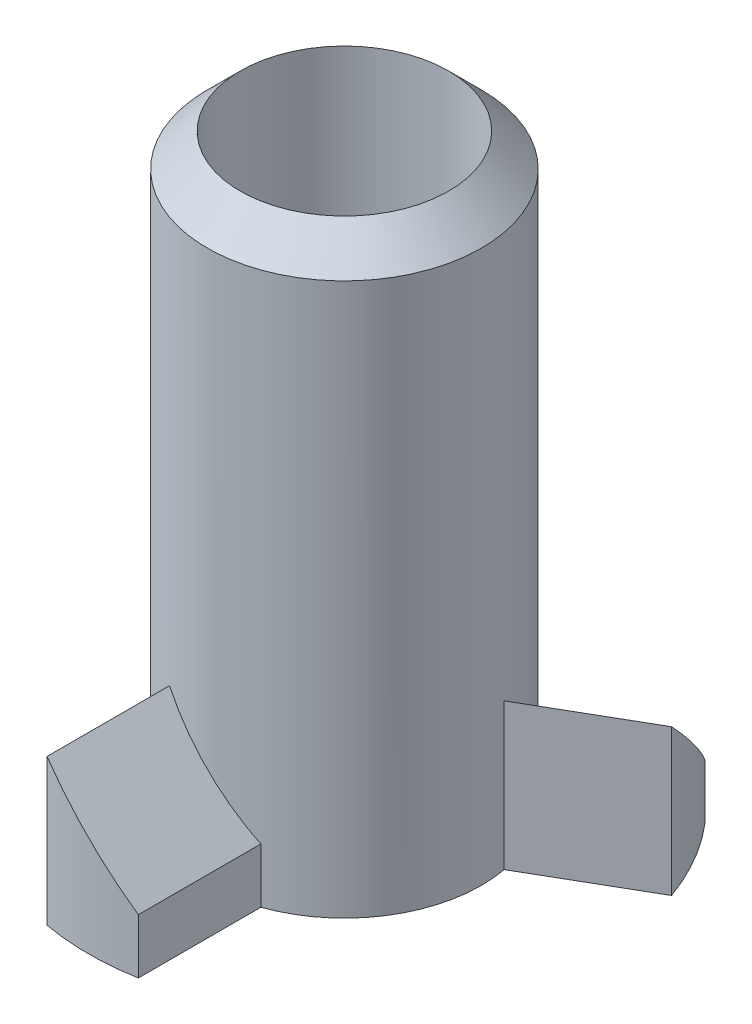
from build123d import *

# Parameters (mm, degrees)
AUFSATZ_LINEAR_AUSTRAGEN1_DEPTH = 2
SCHNITT_LINEAR_AUSTRAGEN1_DEPTH = 4.5
KREISMUSTER1_COUNT              = 3


with BuildPart() as part:
    # Skizze1 → Rotation1 (revolve)
    with BuildSketch(Plane.XY, mode=Mode.PRIVATE) as rotation1_sk:
        Polygon((1.425, 0), (1.425, 8), (1.875, 7.55), (1.875, 0), align=None)
    revolve(rotation1_sk.sketch.rotate(Axis((0, 0, 0), (0, 1, 0)), 90), axis=Axis((0, 0, 0), (0, 1, 0)))  # turned: the seam where the file's is


with BuildPart() as body_2:
    # Skizze2 → Aufsatz-Linear austragen1 (new body)
    with BuildSketch(Plane(origin=(0, 0, 0), x_dir=(1, 0, 0), z_dir=(0, 1, 0))):
        with BuildLine():
            Line((-0.625, -3.443744328), (-0.625, -1.767766953))
            ThreePointArc((-0.625, -1.767766953), (0, -1.875), (0.625, -1.767766953))
            Line((0.625, -1.767766953), (0.625, -3.443744328))
            ThreePointArc((0.625, -3.443744328), (0, -3.5), (-0.625, -3.443744328))
        make_face()
    extrude(amount=AUFSATZ_LINEAR_AUSTRAGEN1_DEPTH)

    # Skizze3 → Schnitt-Linear austragen1 (cut, through all)
    with BuildSketch(Plane.XY):
        Polygon((-0.625, 2), (0.625, 0.75), (0.625, 2), align=None)
    extrude(amount=SCHNITT_LINEAR_AUSTRAGEN1_DEPTH, mode=Mode.SUBTRACT)


with BuildPart() as kreismuster1_1:
    # Kreismuster1: pattern copy
    add(body_2.part.rotate(Axis((0, 0, 0), (0, 1, 0)), 1 * 360 / KREISMUSTER1_COUNT))


with BuildPart() as kreismuster1_2:
    # Kreismuster1: pattern copy
    add(body_2.part.rotate(Axis((0, 0, 0), (0, 1, 0)), 2 * 360 / KREISMUSTER1_COUNT))


with BuildPart() as body_2_1:
    add(body_2.part)

    # Kombinieren1: union part, Kreismuster1_1, Kreismuster1_2
    add(part.part)
    add(kreismuster1_1.part)
    add(kreismuster1_2.part)


solid = body_2_1.part
